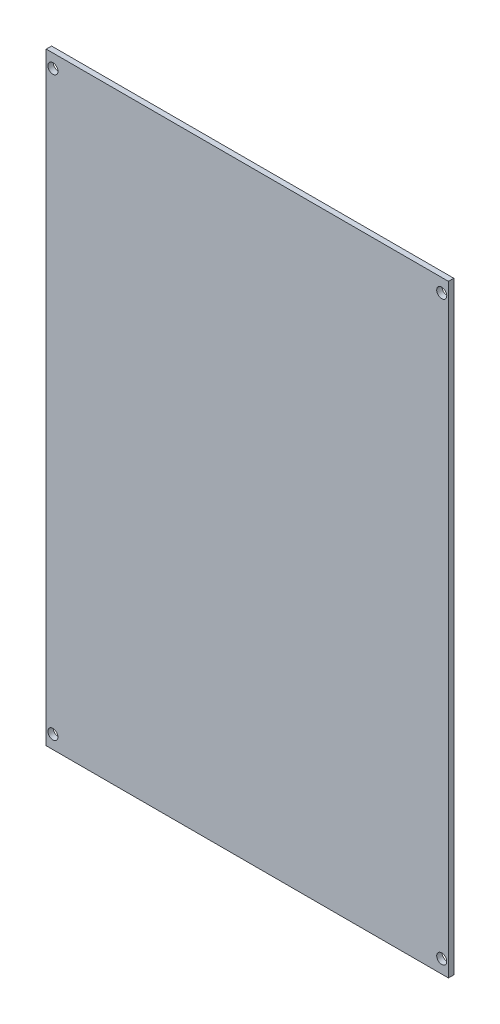
from build123d import *

# Parameters (mm, degrees)
SKETCH1_W               = 120
SKETCH1_H               = 180
BOSS_EXTRUDE1_DEPTH     = 1.6
SKETCH2_R               = 1.5
CUT_EXTRUDE2_DEPTH      = 2.6
CUT_EXTRUDE2_DEPTH_BACK = 1


with BuildPart() as part:
    # Sketch1 → Boss-Extrude1 (new body)
    with BuildSketch(Plane.XY):
        Rectangle(SKETCH1_W, SKETCH1_H)
    extrude(amount=BOSS_EXTRUDE1_DEPTH)

    # Sketch2 → Cut-Extrude2 (cut, two sides)
    with BuildSketch(Plane.XY) as cut_extrude2_sk:
        with Locations((-58, 86)):
            Circle(SKETCH2_R)
        with Locations((58, 86)):
            Circle(SKETCH2_R)
        with Locations((58, -86)):
            Circle(SKETCH2_R)
        with Locations((-58, -86)):
            Circle(SKETCH2_R)
    extrude(amount=CUT_EXTRUDE2_DEPTH, mode=Mode.SUBTRACT)
    extrude(cut_extrude2_sk.sketch, amount=-CUT_EXTRUDE2_DEPTH_BACK, mode=Mode.SUBTRACT)


solid = part.part
